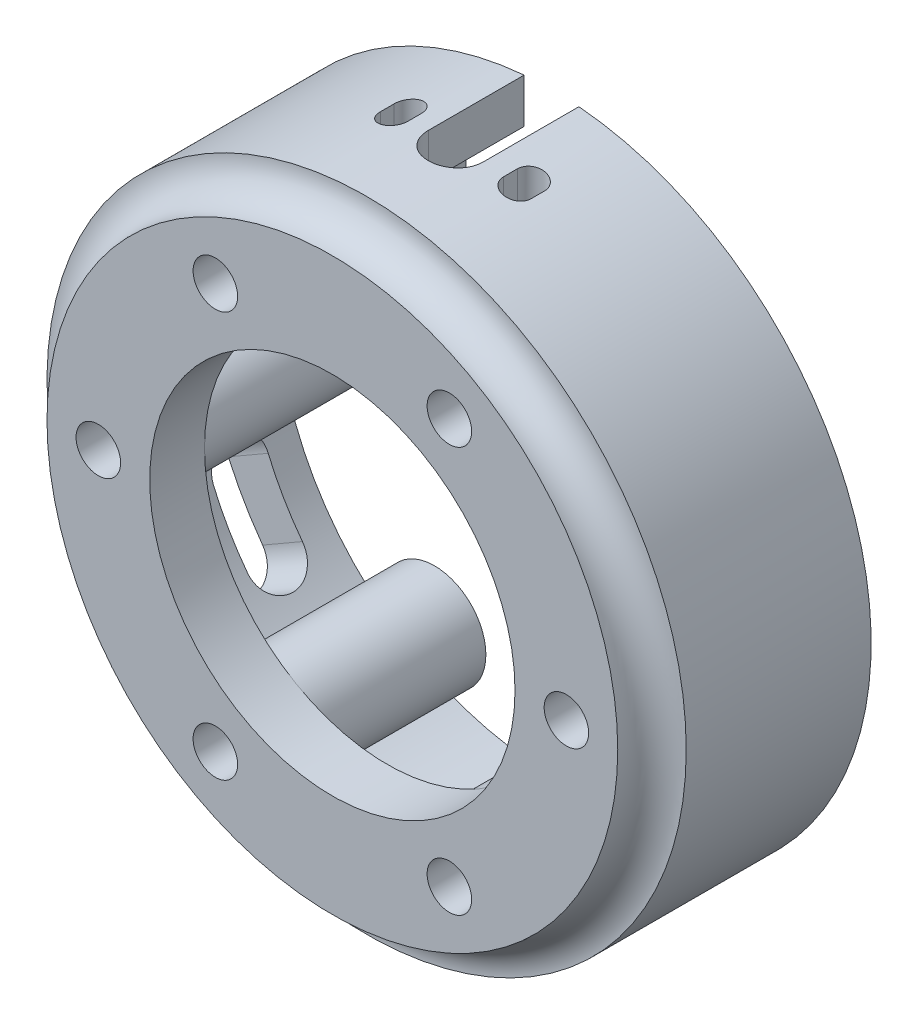
from build123d import *

# Parameters (mm, degrees)
SKETCH2_R           = 23.335
SKETCH2_R_2         = 13.335
BOSS_EXTRUDE1_DEPTH = 3.5
SKETCH3_R           = 2.5
SKETCH6_R           = 23.335
SKETCH6_R_2         = 13.335
BOSS_EXTRUDE2_DEPTH = 12.5
SKETCH4_R           = 1.625
CUT_EXTRUDE1_DEPTH  = 17
SKETCH10_W          = 12.5
SKETCH10_H          = 11
CUT_EXTRUDE3_DEPTH  = 20
CUT_EXTRUDE4_DEPTH  = 24.335
CUT_EXTRUDE7_START  = 11.779632
SKETCH14_W          = 12.5
SKETCH14_H          = 1
CUT_EXTRUDE7_DEPTH  = 8.220368
SKETCH16_W          = 4
SKETCH16_H          = 6
CUT_EXTRUDE9_DEPTH  = 4.335000135
CUT_EXTRUDE10_DEPTH = 32.876202934
CUT_EXTRUDE11_DEPTH = 12


with BuildPart() as part:
    # Sketch2 → Boss-Extrude1 (new body)
    with BuildSketch(Plane.XY):
        Circle(SKETCH2_R)
        Circle(SKETCH2_R_2, mode=Mode.SUBTRACT)
    extrude(amount=BOSS_EXTRUDE1_DEPTH)

    # Sketch3 → Cut-Revolve1 (revolve, cut)
    with BuildSketch(Plane(origin=(0, 0, 0), x_dir=(1, 0, 0), z_dir=(0, 1, 0))):
        with Locations((-23.335, -3.5)):
            Circle(SKETCH3_R)
    revolve(axis=Axis((0, 0, 3.5), (0, 0, -1)), mode=Mode.SUBTRACT)

    # Sketch6 → Boss-Extrude2 (add)
    with BuildSketch(Plane(origin=(0, 0, 0), x_dir=(-1, 0, 0), z_dir=(0, 0, -1))):
        Circle(SKETCH6_R)
        Circle(SKETCH6_R_2, mode=Mode.SUBTRACT)
    extrude(amount=BOSS_EXTRUDE2_DEPTH)

    # Sketch4 → Cut-Extrude1 (cut, through all)
    with BuildSketch(Plane(origin=(0, 0, 3.5), x_dir=(-1, 0, 0), z_dir=(0, 0, -1))):
        with Locations((8.5425, 14.796044024)):
            Circle(SKETCH4_R)
        with Locations((-8.5425, 14.796044024)):
            Circle(SKETCH4_R)
        with Locations((-17.085, 0)):
            Circle(SKETCH4_R)
        with Locations((-8.5425, -14.796044024)):
            Circle(SKETCH4_R)
        with Locations((8.5425, -14.796044024)):
            Circle(SKETCH4_R)
        with Locations((17.085, 0)):
            Circle(SKETCH4_R)
    extrude(amount=CUT_EXTRUDE1_DEPTH, mode=Mode.SUBTRACT)

    # Sketch10 → Cut-Extrude3 (cut)
    with BuildSketch(Plane(origin=(0, 0, 0), x_dir=(1, 0, 0), z_dir=(0, 1, 0))):
        with Locations((0, 6)):
            Rectangle(SKETCH10_W, SKETCH10_H)
        with BuildLine():
            ThreePointArc((5.5, 6.5), (4.5, 7.5), (3.5, 6.5))
            Line((3.5, 6.5), (3.5, 5.5))
            ThreePointArc((3.5, 5.5), (4.5, 4.5), (5.5, 5.5))
            Line((5.5, 5.5), (5.5, 6.5))
        make_face(mode=Mode.SUBTRACT)
        with BuildLine():
            ThreePointArc((-5.5, 5.5), (-4.5, 4.5), (-3.5, 5.5))
            Line((-3.5, 5.5), (-3.5, 6.5))
            ThreePointArc((-3.5, 6.5), (-4.5, 7.5), (-5.5, 6.5))
            Line((-5.5, 6.5), (-5.5, 5.5))
        make_face(mode=Mode.SUBTRACT)
        with BuildLine():
            ThreePointArc((-2, 5.5), (0, 3.5), (2, 5.5))
            Line((2, 5.5), (2, 6.5))
            ThreePointArc((2, 6.5), (0, 8.5), (-2, 6.5))
            Line((-2, 6.5), (-2, 5.5))
        make_face(mode=Mode.SUBTRACT)
        with BuildLine():
            Line((5.5, 5.5), (5.5, 6.5))
            ThreePointArc((5.5, 6.5), (4.5, 7.5), (3.5, 6.5))
            Line((3.5, 6.5), (3.5, 5.5))
            ThreePointArc((3.5, 5.5), (4.5, 4.5), (5.5, 5.5))
        make_face()
        with BuildLine():
            Line((-2, 6.5), (-2, 5.5))
            ThreePointArc((-2, 5.5), (0, 3.5), (2, 5.5))
            Line((2, 5.5), (2, 6.5))
            ThreePointArc((2, 6.5), (0, 8.5), (-2, 6.5))
        make_face()
        with BuildLine():
            Line((-5.5, 6.5), (-5.5, 5.5))
            ThreePointArc((-5.5, 5.5), (-4.5, 4.5), (-3.5, 5.5))
            Line((-3.5, 5.5), (-3.5, 6.5))
            ThreePointArc((-3.5, 6.5), (-4.5, 7.5), (-5.5, 6.5))
        make_face()
    extrude(amount=CUT_EXTRUDE3_DEPTH, mode=Mode.SUBTRACT)

    # Sketch10_3 → Cut-Extrude4 (cut, through all)
    with BuildSketch(Plane(origin=(0, 0, 0), x_dir=(1, 0, 0), z_dir=(0, 1, 0))):
        with BuildLine():
            Line((5.5, 5.5), (5.5, 6.5))
            ThreePointArc((5.5, 6.5), (4.5, 7.5), (3.5, 6.5))
            Line((3.5, 6.5), (3.5, 5.5))
            ThreePointArc((3.5, 5.5), (4.5, 4.5), (5.5, 5.5))
        make_face()
        with BuildLine():
            Line((-2, 6.5), (-2, 5.5))
            ThreePointArc((-2, 5.5), (0, 3.5), (2, 5.5))
            Line((2, 5.5), (2, 6.5))
            ThreePointArc((2, 6.5), (0, 8.5), (-2, 6.5))
        make_face()
        with BuildLine():
            Line((-5.5, 6.5), (-5.5, 5.5))
            ThreePointArc((-5.5, 5.5), (-4.5, 4.5), (-3.5, 5.5))
            Line((-3.5, 5.5), (-3.5, 6.5))
            ThreePointArc((-3.5, 6.5), (-4.5, 7.5), (-5.5, 6.5))
        make_face()
    extrude(amount=CUT_EXTRUDE4_DEPTH, mode=Mode.SUBTRACT)

    # Sketch14 → Cut-Extrude7 (cut)
    with BuildSketch(Plane(origin=(0, 0, 0), x_dir=(1, 0, 0), z_dir=(0, 1, 0)).offset(CUT_EXTRUDE7_START)):
        with Locations((0, 12)):
            Rectangle(SKETCH14_W, SKETCH14_H)
    extrude(amount=CUT_EXTRUDE7_DEPTH, mode=Mode.SUBTRACT)

    # Sketch16 → Cut-Extrude9 (cut, through all)
    with BuildSketch(Plane.XZ.offset(-20)):
        with Locations((0, -9.5)):
            Rectangle(SKETCH16_W, SKETCH16_H)
    extrude(amount=-CUT_EXTRUDE9_DEPTH, mode=Mode.SUBTRACT)

    # Sketch17 → Cut-Extrude10 (cut, through all)
    with BuildSketch(Plane(origin=(0, 0, 0), x_dir=(0, 0, -1), z_dir=(-0.866025404, -0.5, 0))):
        with BuildLine():
            Line((10.25, 2.5), (10.25, -2.5))
            ThreePointArc((10.25, -2.5), (8.25, -4.5), (6.25, -2.5))
            Line((6.25, -2.5), (6.25, 2.5))
            ThreePointArc((6.25, 2.5), (8.25, 4.5), (10.25, 2.5))
        make_face()
    extrude(amount=CUT_EXTRUDE10_DEPTH, mode=Mode.SUBTRACT)

    # Sketch18 → Cut-Extrude11 (cut)
    with BuildSketch(Plane(origin=(0, 0, -12.5), x_dir=(-1, 0, 0), z_dir=(0, 0, -1))):
        with BuildLine():
            Line((-6.25, 11.779631785), (-6.25, 18.998355192))
            ThreePointArc((-6.25, 18.998355192), (0, 20), (6.25, 18.998355192))
            Line((6.25, 18.998355192), (6.25, 11.779631785))
            ThreePointArc((6.25, 11.779631785), (10.692886041, 11.676726964), (12.177094021, 15.865635229))
            ThreePointArc((12.177094021, 15.865635229), (17.337033787, 9.971321851), (19.837129792, 2.547210554))
            ThreePointArc((19.837129792, 2.547210554), (13.335, 0), (19.837129792, -2.547210554))
            ThreePointArc((19.837129792, -2.547210554), (17.320508076, -10), (12.124513945, -15.905853061))
            ThreePointArc((12.124513945, -15.905853061), (6.6675, -11.548448759), (7.712615847, -18.453063615))
            ThreePointArc((7.712615847, -18.453063615), (0, -20), (-7.712615847, -18.453063615))
            ThreePointArc((-7.712615847, -18.453063615), (-6.6675, -11.548448759), (-12.124513945, -15.905853061))
            ThreePointArc((-12.124513945, -15.905853061), (-17.320508076, -10), (-19.837129792, -2.547210554))
            ThreePointArc((-19.837129792, -2.547210554), (-13.335, 0), (-19.837129792, 2.547210554))
            ThreePointArc((-19.837129792, 2.547210554), (-17.337033787, 9.971321851), (-12.177094021, 15.865635229))
            ThreePointArc((-12.177094021, 15.865635229), (-10.692886041, 11.676726964), (-6.25, 11.779631785))
        make_face()
    extrude(amount=-CUT_EXTRUDE11_DEPTH, mode=Mode.SUBTRACT)


solid = part.part
